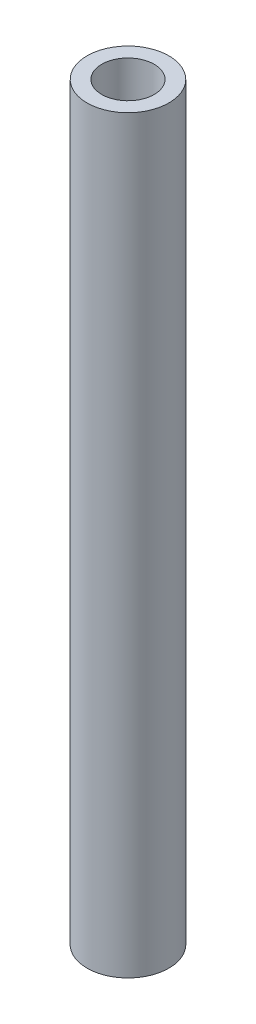
from build123d import *

# Parameters (mm, degrees)
ESQUISSE1_R             = 6
BOSS_EXTRU_1_DEPTH      = 110
ESQUISSE1_3_R           = 3.85
ENL_V_MAT_EXTRU_1_DEPTH = 110


with BuildPart() as part:
    # Esquisse1 → Boss.-Extru.1 (new body)
    with BuildSketch(Plane(origin=(0, 0, 0), x_dir=(1, 0, 0), z_dir=(0, 1, 0))):
        with Locations((-34.390392651, -12.56102994)):
            Circle(ESQUISSE1_R)
    extrude(amount=BOSS_EXTRU_1_DEPTH)

    # Esquisse1_3 → Enl_v. mat.-Extru.1 (cut)
    with BuildSketch(Plane(origin=(0, 0, 0), x_dir=(1, 0, 0), z_dir=(0, 1, 0))):
        with Locations((-34.390392651, -12.56102994)):
            Circle(ESQUISSE1_3_R)
    extrude(amount=ENL_V_MAT_EXTRU_1_DEPTH, mode=Mode.SUBTRACT)


solid = part.part
